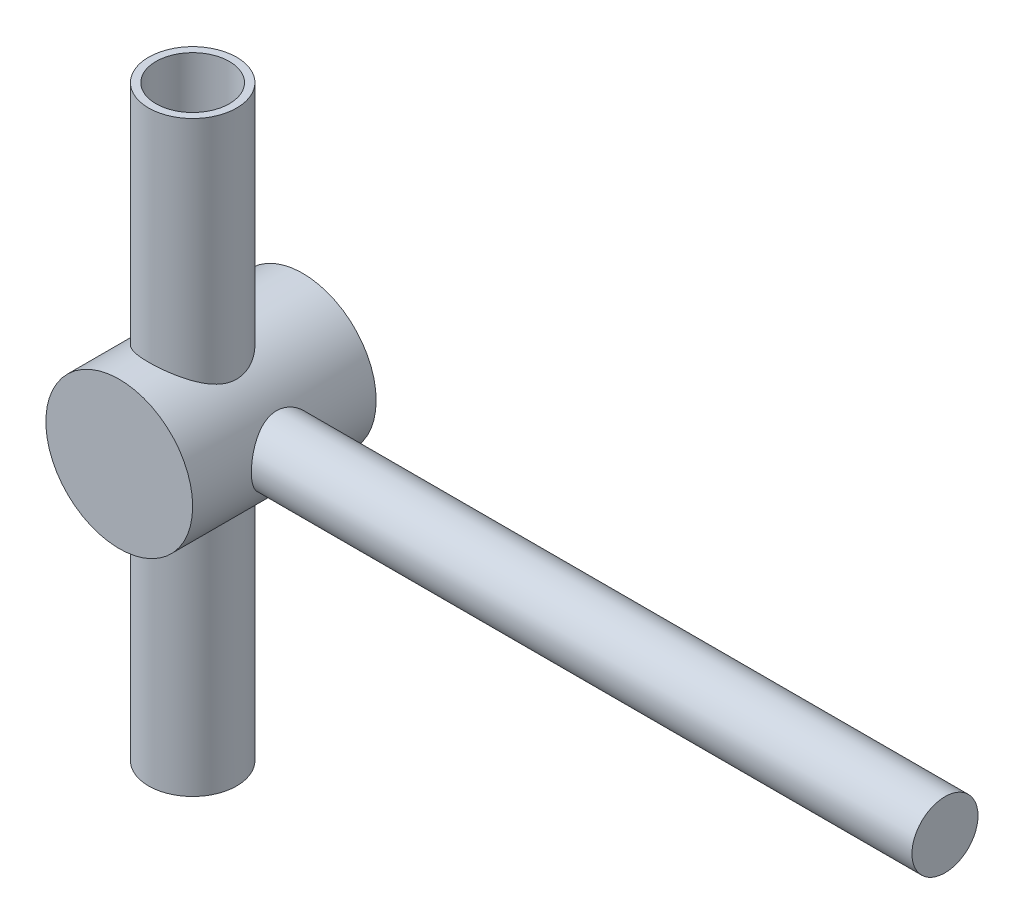
from build123d import *

# Parameters (mm, degrees)
SKETCH1_R           = 5
BOSS_EXTRUDE1_DEPTH = 6.25
SKETCH2_R           = 3
BOSS_EXTRUDE2_DEPTH = 20
SKETCH3_R           = 2.25
BOSS_EXTRUDE3_DEPTH = 50
SKETCH4_R           = 2.5
CUT_EXTRUDE1_DEPTH  = 40
CUT_EXTRUDE2_START  = -12.5
SKETCH5_R           = 3.75
CUT_EXTRUDE2_DEPTH  = 10


with BuildPart() as part:
    # Sketch1 → Boss-Extrude1 (new body, symmetric)
    with BuildSketch(Plane.XY):
        Circle(SKETCH1_R)
    extrude(amount=BOSS_EXTRUDE1_DEPTH, both=True)

    # Sketch2 → Boss-Extrude2 (add, symmetric)
    with BuildSketch(Plane(origin=(0, 0, 0), x_dir=(1, 0, 0), z_dir=(0, 1, 0))):
        with Locations((0, -1.25)):
            Circle(SKETCH2_R)
    extrude(amount=BOSS_EXTRUDE2_DEPTH, both=True)

    # Sketch3 → Boss-Extrude3 (add)
    with BuildSketch(Plane(origin=(0, 0, 0), x_dir=(0, 0, -1), z_dir=(1, 0, 0))):
        Circle(SKETCH3_R)
    extrude(amount=BOSS_EXTRUDE3_DEPTH)

    # Sketch4 → Cut-Extrude1 (cut)
    with BuildSketch(Plane.XZ.offset(20)):
        with Locations((0, 1.25)):
            Circle(SKETCH4_R)
    extrude(amount=-CUT_EXTRUDE1_DEPTH, mode=Mode.SUBTRACT)

    # Sketch5 → Cut-Extrude2 (cut)
    with BuildSketch(Plane.XY.offset(6.25).offset(CUT_EXTRUDE2_START)):
        Circle(SKETCH5_R)
    extrude(amount=CUT_EXTRUDE2_DEPTH, mode=Mode.SUBTRACT)


solid = part.part
